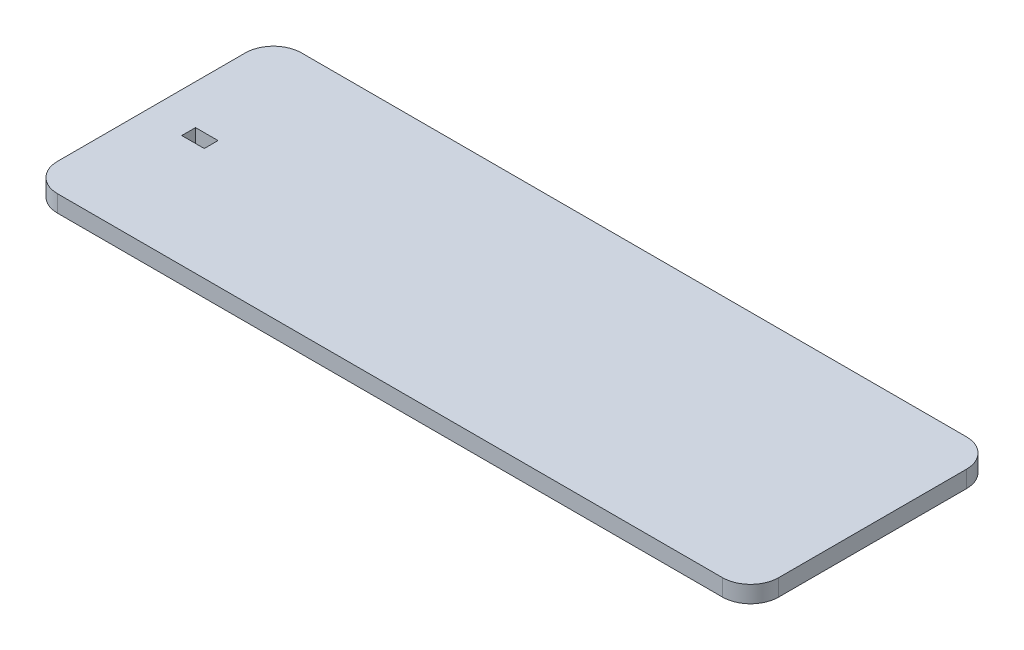
from build123d import *

# Parameters (mm, degrees)
SKETCH2_W               = 256.44751275
SKETCH2_H               = 86.763856324
BOSS_EXTRUDE2_DEPTH     = 6
SKETCH5_W               = 8
SKETCH5_H               = 4.9
CUT_EXTRUDE7_DEPTH      = 1
CUT_EXTRUDE7_DEPTH_BACK = 7
FILLET1_R               = 10


with BuildPart() as part:
    # Sketch2 → Boss-Extrude2 (new body)
    with BuildSketch(Plane(origin=(0, 0, 0), x_dir=(1, 0, 0), z_dir=(0, 1, 0))):
        with Locations((-92.975357556, 78.4180884)):
            Rectangle(SKETCH2_W, SKETCH2_H)
    extrude(amount=BOSS_EXTRUDE2_DEPTH)

    # Sketch5 → Cut-Extrude7 (cut, two sides)
    with BuildSketch(Plane.XZ) as cut_extrude7_sk:
        with Locations((-203.05, -77.5)):
            Rectangle(SKETCH5_W, SKETCH5_H)
    extrude(amount=CUT_EXTRUDE7_DEPTH, mode=Mode.SUBTRACT)
    extrude(cut_extrude7_sk.sketch, amount=-CUT_EXTRUDE7_DEPTH_BACK, mode=Mode.SUBTRACT)

    # Fillet1
    fillet1_edges = [part.edges().sort_by_distance(p)[0] for p in [
        (35.248398819, 3, -35.036160238),
        (-221.199113931, 3, -35.036160238),
        (-221.199113931, 3, -121.800016562),
        (35.248398819, 3, -121.800016562),
    ]]
    fillet(fillet1_edges, radius=FILLET1_R)


solid = part.part
